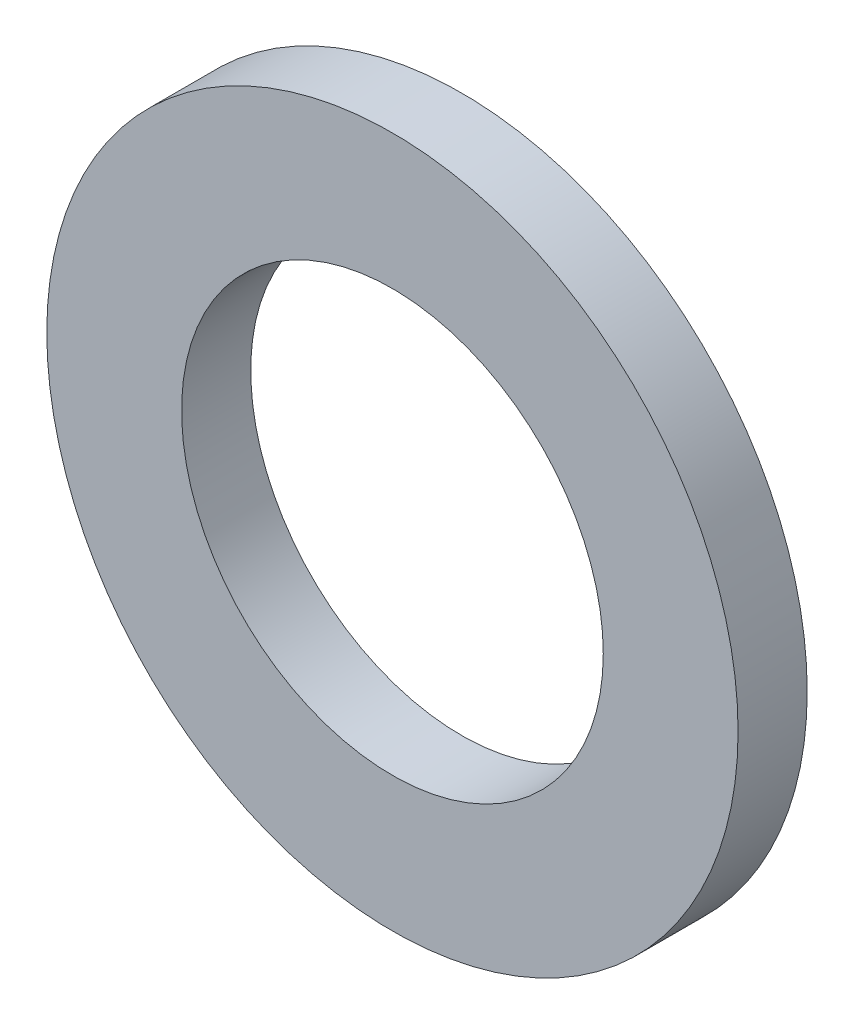
from build123d import *

# Parameters (mm, degrees)
SKETCH1_R           = 5
SKETCH1_R_2         = 3.05
BOSS_EXTRUDE1_DEPTH = 1


with BuildPart() as part:
    # Sketch1 → Boss-Extrude1 (new body)
    with BuildSketch(Plane.XY):
        Circle(SKETCH1_R)
        Circle(SKETCH1_R_2, mode=Mode.SUBTRACT)
    extrude(amount=BOSS_EXTRUDE1_DEPTH)


solid = part.part
